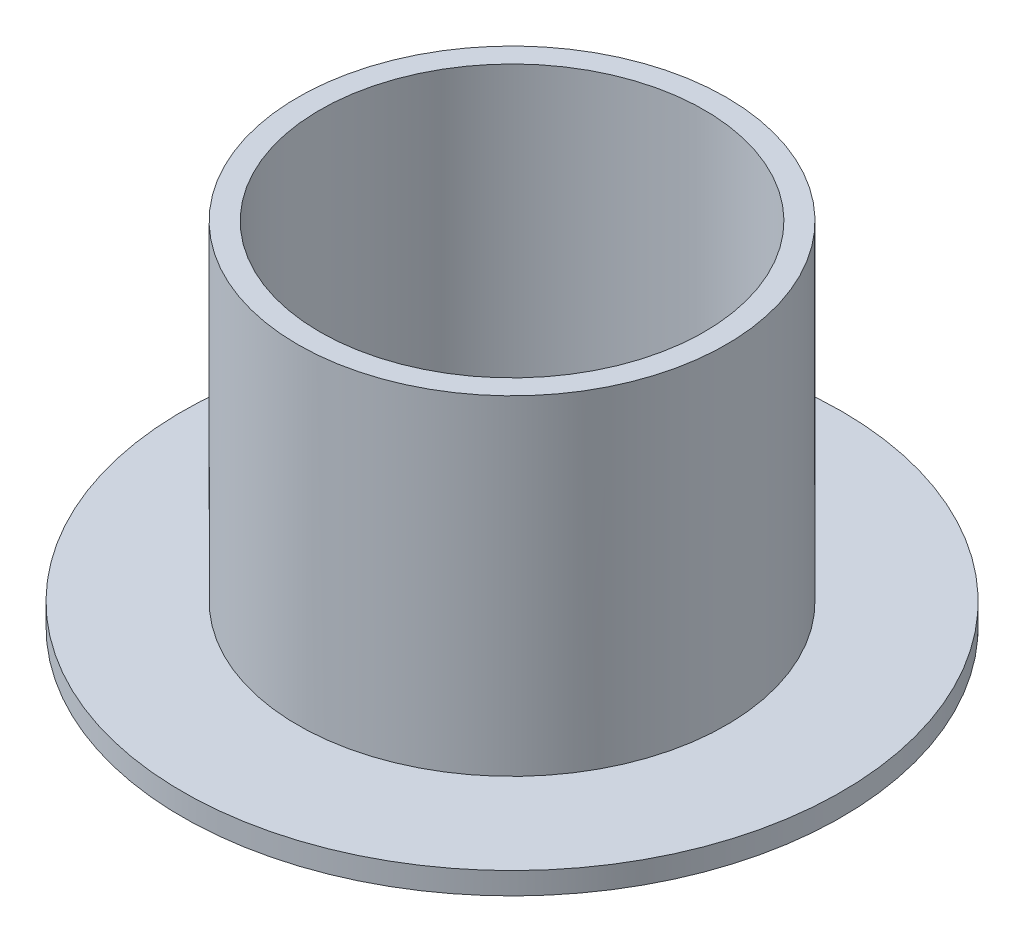
from build123d import *

# Parameters (mm, degrees)
SKETCH1_R           = 19.5
SKETCH1_R_2         = 17.5
BOSS_EXTRUDE1_DEPTH = 30
SKETCH2_R           = 30
BOSS_EXTRUDE2_DEPTH = 2


with BuildPart() as part:
    # Sketch1 → Boss-Extrude1 (new body)
    with BuildSketch(Plane(origin=(0, 0, 0), x_dir=(1, 0, 0), z_dir=(0, 1, 0))):
        Circle(SKETCH1_R)
        Circle(SKETCH1_R_2, mode=Mode.SUBTRACT)
    extrude(amount=BOSS_EXTRUDE1_DEPTH)

    # Sketch2 → Boss-Extrude2 (add)
    with BuildSketch(Plane.XZ):
        Circle(SKETCH2_R)
    extrude(amount=BOSS_EXTRUDE2_DEPTH)


solid = part.part
